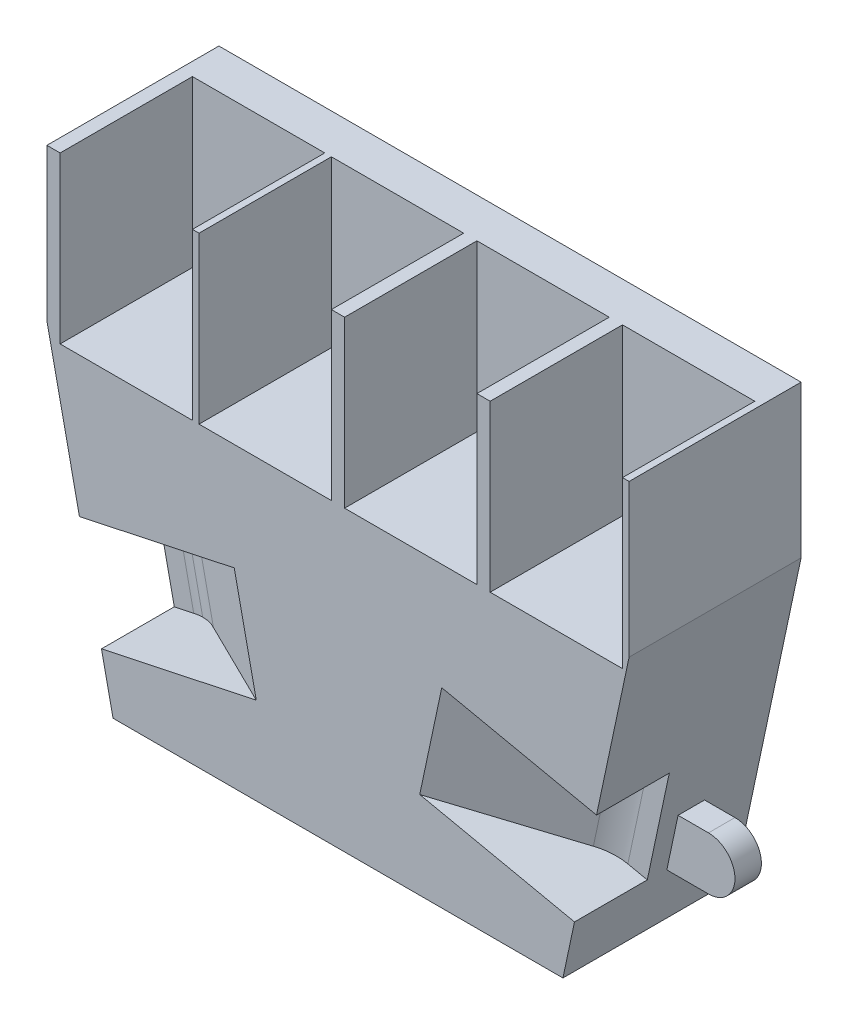
from build123d import *

# Parameters (mm, degrees)
EXTRUDE_1_DEPTH      = 26
SKETCH_3_W           = 40
SKETCH_3_H           = 36
CUT_EXTRUDE_4_DEPTH  = 20
SKETCH_4_W           = 20
SKETCH_4_H           = 20
CUT_EXTRUDE_5_DEPTH  = 25
CUT_EXTRUDE_3_DEPTH  = 8
CUT_EXTRUDE_6_DEPTH  = 8
CUT_EXTRUDE_7_DEPTH  = 16
CUT_EXTRUDE_8_DEPTH  = 16
CUT_EXTRUDE_9_DEPTH  = 6
EXTRUDE_2_DEPTH      = 12
CUT_EXTRUDE_10_DEPTH = 8


with BuildPart() as part:
    # 草图1 → 凸台-拉伸1 (new body)
    with BuildSketch(Plane.XY):
        Polygon((-34, -24), (34, -24), (44, 23), (44, 46), (-44, 46), (-44, 23), align=None)
    extrude(amount=EXTRUDE_1_DEPTH)

    # 草图3 → 切除-拉伸4 (cut)
    with BuildSketch(Plane(origin=(0, 0, 0), x_dir=(-1, 0, 0), z_dir=(0, 0, -1))):
        with Locations((0, -6)):
            Rectangle(SKETCH_3_W, SKETCH_3_H)
    extrude(amount=-CUT_EXTRUDE_4_DEPTH, mode=Mode.SUBTRACT)

    # 草图4 → 切除-拉伸5 (cut)
    with BuildSketch(Plane(origin=(0, 46, 0), x_dir=(1, 0, 0), z_dir=(0, 1, 0))):
        with Locations((33, -16)):
            Rectangle(SKETCH_4_W, SKETCH_4_H)
        with Locations((11, -16)):
            Rectangle(SKETCH_4_W, SKETCH_4_H)
        with Locations((-11, -16)):
            Rectangle(SKETCH_4_W, SKETCH_4_H)
        with Locations((-32, -16)):
            Rectangle(SKETCH_4_W, SKETCH_4_H)
    extrude(amount=-CUT_EXTRUDE_5_DEPTH, mode=Mode.SUBTRACT)

    # Sketch 3D_5 → 切除-拉伸3 (cut, symmetric)
    with BuildSketch(Plane(origin=(-26.633413551, -5.666683734, 23.004025099), x_dir=(-0.691625335103945, -0.14715432661786076, 0.7071067811865475), z_dir=(-0.2081076444648591, 0.9781059289848354, 0))):
        with BuildLine():
            Line((0, 0), (5.656854249, 5.656854249))
            Line((5.656854249, 5.656854249), (11.313708499, 0))
            ThreePointArc((11.313708499, 0), (5.656854249, -13.656854249), (0, 0))
        make_face()
    extrude(amount=CUT_EXTRUDE_3_DEPTH, both=True, mode=Mode.SUBTRACT)

    # Sketch 3D_6 → 切除-拉伸6 (cut, symmetric)
    with BuildSketch(Plane(origin=(34.478414998, -7.335832978, 14.99907516), x_dir=(0.5895982688198705, -0.12544644017993214, 0.7978954016979886), z_dir=(-0.20810764446495697, -0.9781059289848145, -6.6559639472978385e-12))):
        with BuildLine():
            Line((0, 0), (6.376045072, -8.439700449))
            Line((6.376045072, -8.439700449), (17.547318622, 0))
            Line((17.547318622, 0), (11.17127355, 8.439700449))
            Line((11.17127355, 8.439700449), (6.348906145, 14.822863662))
            Line((6.348906145, 14.822863662), (1.560795809, 11.205530619))
            ThreePointArc((1.560795809, 11.205530619), (-1.540343474, 5.926016705), (0, 0))
        make_face()
    extrude(amount=CUT_EXTRUDE_6_DEPTH, both=True, mode=Mode.SUBTRACT)

    # 草图7 → 切除-拉伸7 (cut)
    with BuildSketch(Plane(origin=(-1.664861156, 7.824847432, 0), x_dir=(0.9781059289848355, 0.2081076444648587, 0), z_dir=(0.2081076444648587, -0.9781059289848355, 0))):
        with BuildLine():
            Line((-24.556702047, 20), (-31.200844281, 16.10051891))
            ThreePointArc((-31.200844281, 16.10051891), (-33.152072653, 15.280030806), (-35.250185053, 15))
            Line((-35.250185053, 15), (-43.250185053, 15))
            Line((-43.250185053, 15), (-43.250185053, 23))
            ThreePointArc((-43.250185053, 23), (-40.3181561, 29.189965223), (-33.671267687, 30.842641134))
            Line((-33.671267687, 30.842641134), (-10.087245225, 28.492198282))
            Line((-10.087245225, 28.492198282), (-24.556702047, 20))
        make_face()
    extrude(amount=CUT_EXTRUDE_7_DEPTH, mode=Mode.SUBTRACT)

    # 草图11 → 切除-拉伸8 (cut)
    with BuildSketch(Plane(origin=(-1.664861156, -7.824847432, 0), x_dir=(0.9781059289845859, -0.2081076444660318, -1.1269708570671002e-12), z_dir=(0.20810764446603178, 0.9781059289845858, 5.296763028184159e-12))):
        with BuildLine():
            Line((31.200844283, -16.100518909), (14.333584528, -26))
            Line((14.333584528, -26), (32.666556858, -30.571318601))
            ThreePointArc((32.666556858, -30.571318601), (42.196349228, -26.968728166), (40.460809076, -16.92962956))
            Line((40.460809076, -16.92962956), (38.250185053, -14.99907516))
            Line((38.250185053, -14.99907516), (35.250185053, -15))
            ThreePointArc((35.250185053, -15), (33.152072655, -15.280030806), (31.200844283, -16.100518909))
        make_face()
    extrude(amount=CUT_EXTRUDE_8_DEPTH, mode=Mode.SUBTRACT)

    # 草图12 → 切除-拉伸9 (cut)
    with BuildSketch(Plane(origin=(0, 0, 0), x_dir=(-1, 0, 0), z_dir=(0, 0, -1))):
        with BuildLine():
            Line((34, -16), (36.935033059, -16))
            Line((36.935033059, -16), (34, -24))
            Line((34, -24), (26, -24))
            Line((26, -24), (26, -20))
            ThreePointArc((26, -20), (27.171572875, -17.171572875), (30, -16))
            Line((30, -16), (34, -16))
        make_face()
    extrude(amount=-CUT_EXTRUDE_9_DEPTH, mode=Mode.SUBTRACT)

    # 草图13 → 凸台-拉伸2 (add)
    with BuildSketch(Plane(origin=(0, 0, 0), x_dir=(-1, 0, 0), z_dir=(0, 0, -1))):
        with BuildLine():
            Line((-34, -8), (-42, -8))
            ThreePointArc((-42, -8), (-46, -12), (-42, -16))
            Line((-42, -16), (-34, -16))
            Line((-34, -16), (-34, -8))
        make_face()
    extrude(amount=-EXTRUDE_2_DEPTH)

    # 草图14 → 切除-拉伸10 (cut)
    with BuildSketch(Plane(origin=(0, 0, 0), x_dir=(-1, 0, 0), z_dir=(0, 0, -1))):
        Polygon((-37.404255319, -8), (-35.70212766, -16), (-61.438279543, -16), (-61.438279543, -8), align=None)
    extrude(amount=-CUT_EXTRUDE_10_DEPTH, mode=Mode.SUBTRACT)


solid = part.part
